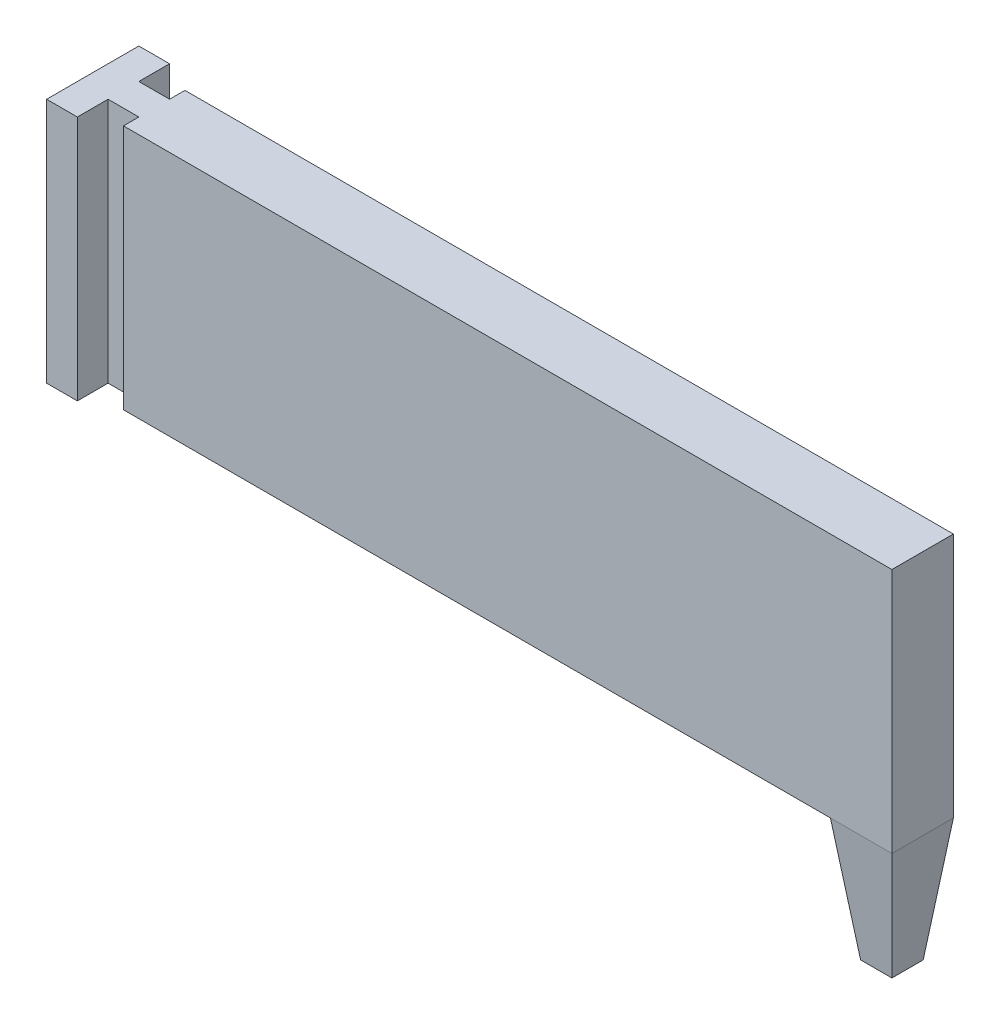
from build123d import *

# Parameters (mm, degrees)
BOSS_EXTRUDE1_DEPTH      = 40
SKETCH3_W                = 125
SKETCH3_H                = 40
BOSS_EXTRUDE2_DEPTH      = 5
BOSS_EXTRUDE2_DEPTH_BACK = 5
SKETCH4_W                = 10
SKETCH4_H                = 10
BOSS_EXTRUDE3_DEPTH      = 20
BOSS_EXTRUDE3_TAPER      = 7


with BuildPart() as part:
    # Sketch2 → Boss-Extrude1 (new body)
    with BuildSketch(Plane(origin=(0, 0, 0), x_dir=(1, 0, 0), z_dir=(0, 1, 0))):
        Polygon((-10, 7.5), (-10, -7.5), (-5, -7.5), (-5, -2.5), (0, -2.5), (0, 2.5), (-5, 2.5), (-5, 7.5), align=None)
    extrude(amount=BOSS_EXTRUDE1_DEPTH)

    # Sketch3 → Boss-Extrude2 (add, two sides)
    with BuildSketch(Plane.XY) as boss_extrude2_sk:
        with Locations((62.5, 20)):
            Rectangle(SKETCH3_W, SKETCH3_H)
    extrude(amount=BOSS_EXTRUDE2_DEPTH)
    extrude(boss_extrude2_sk.sketch, amount=-BOSS_EXTRUDE2_DEPTH_BACK)

    # Sketch4 → Boss-Extrude3 (add)
    with BuildSketch(Plane.XZ):
        with Locations((120, 0)):
            Rectangle(SKETCH4_W, SKETCH4_H)
    extrude(amount=BOSS_EXTRUDE3_DEPTH, taper=BOSS_EXTRUDE3_TAPER)


solid = part.part
